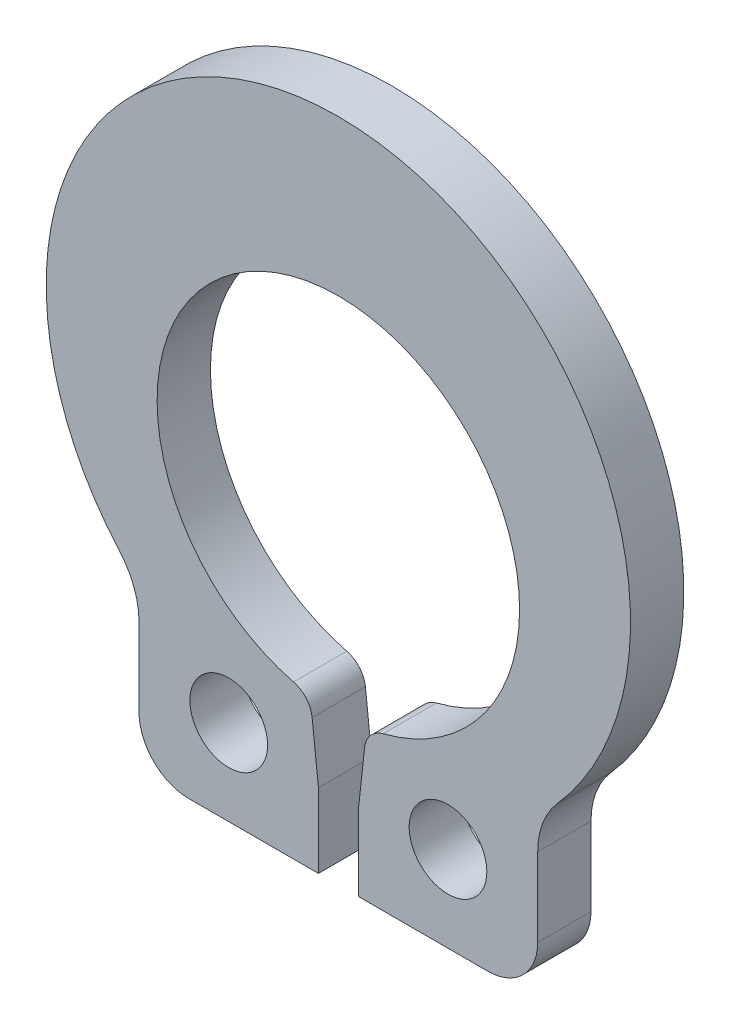
from build123d import *

# Parameters (mm, degrees)
SKETCH3_R               = 0.6477
BOSS_EXTRUDE1_DEPTH     = 0.4445
CUT_EXTRUDE1_DEPTH      = 1.4445
CUT_EXTRUDE1_DEPTH_BACK = 1.4445
FILLET1_R               = 0.4162425


with BuildPart() as part:
    # Sketch3 → Boss-Extrude1 (new body, symmetric)
    with BuildSketch(Plane.XY):
        with BuildLine():
            Line((3.32486, -4.653915), (3.32486, -3.346426518))
            ThreePointArc((3.32486, -3.346426518), (3.408862886, -2.887538523), (3.649976862, -2.488165606))
            ThreePointArc((3.649976862, -2.488165606), (0, 5.6134), (-3.649976862, -2.488165606))
            ThreePointArc((-3.649976862, -2.488165606), (-3.408862886, -2.887538523), (-3.32486, -3.346426518))
            Line((-3.32486, -3.346426518), (-3.32486, -4.653915))
            ThreePointArc((-3.32486, -4.653915), (-3.081030789, -5.242570789), (-2.492375, -5.4864))
            Line((-2.492375, -5.4864), (-0.332486, -5.4864))
            Line((-0.332486, -5.4864), (-0.332486, -3.004257615))
            ThreePointArc((-0.332486, -3.004257615), (0, 3.0226), (0.332486, -3.004257615))
            Line((0.332486, -3.004257615), (0.332486, -5.4864))
            Line((0.332486, -5.4864), (2.492375, -5.4864))
            ThreePointArc((2.492375, -5.4864), (3.081030789, -5.242570789), (3.32486, -4.653915))
        make_face()
        with Locations((-1.828673, -4.057999533)):
            Circle(SKETCH3_R, mode=Mode.SUBTRACT)
        with Locations((1.828673, -4.057999533)):
            Circle(SKETCH3_R, mode=Mode.SUBTRACT)
    extrude(amount=BOSS_EXTRUDE1_DEPTH, both=True)

    # Sketch4 → Cut-Extrude1 (cut, two sides)
    with BuildSketch(Plane.XY) as cut_extrude1_sk:
        Polygon((-0.332486, -4.245328808), (-0.797425121, 0), (0.797425121, 0), (0.332486, -4.245328808), align=None)
    extrude(amount=CUT_EXTRUDE1_DEPTH, mode=Mode.SUBTRACT)
    extrude(cut_extrude1_sk.sketch, amount=-CUT_EXTRUDE1_DEPTH_BACK, mode=Mode.SUBTRACT)

    # Fillet1
    fillet1_edges = [part.edges().sort_by_distance(p)[0] for p in [
        (-0.470430427, -2.985767234, 0),
        (0.470430427, -2.985767234, 0),
    ]]
    fillet(fillet1_edges, radius=FILLET1_R)


solid = part.part
